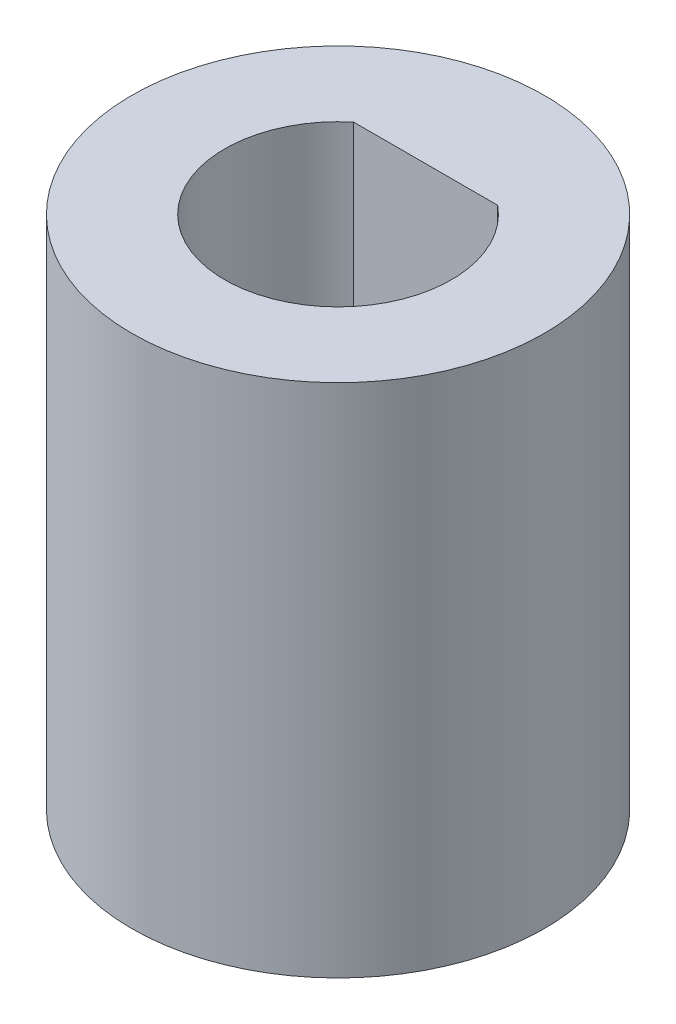
from build123d import *

# Parameters (mm, degrees)
SKETCH1_R           = 4
BOSS_EXTRUDE1_DEPTH = 10


with BuildPart() as part:
    # Sketch1 → Boss-Extrude1 (new body)
    with BuildSketch(Plane(origin=(0, 0, 0), x_dir=(1, 0, 0), z_dir=(0, 1, 0))):
        Circle(SKETCH1_R)
        with BuildLine():
            Line((-1.396424004, 1.7), (1.396424004, 1.7))
            ThreePointArc((1.396424004, 1.7), (0, -2.2), (-1.396424004, 1.7))
        make_face(mode=Mode.SUBTRACT)
    extrude(amount=BOSS_EXTRUDE1_DEPTH)


solid = part.part
